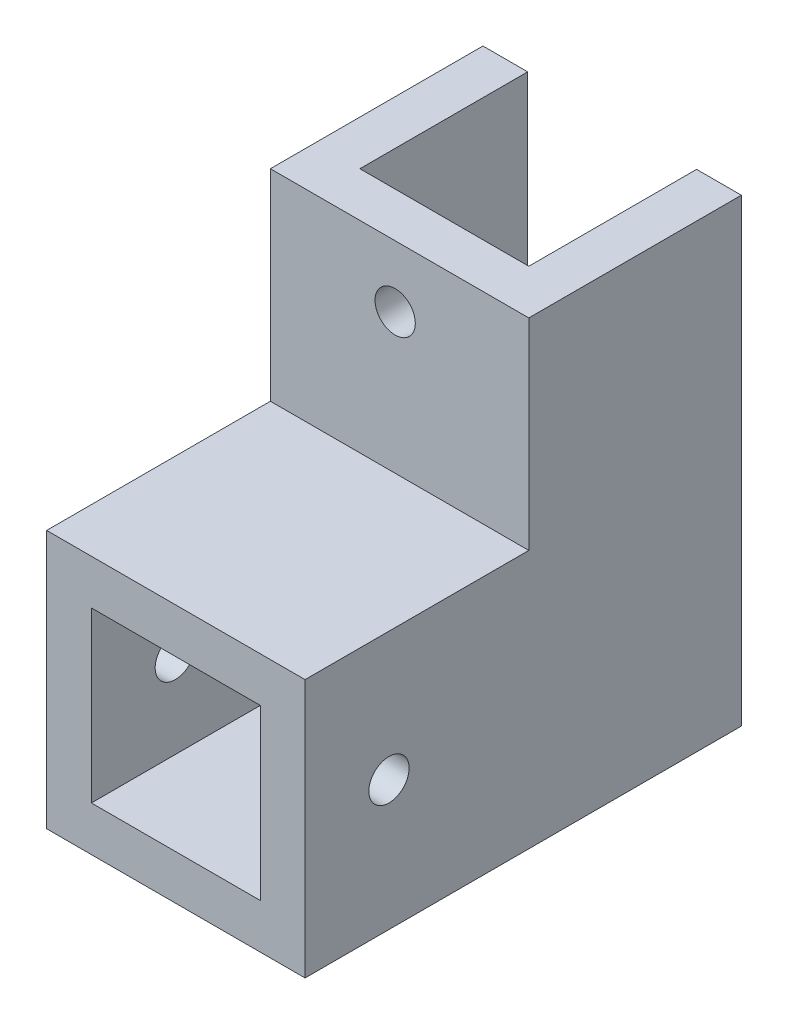
from build123d import *

# Parameters (mm, degrees)
EXTRUDE_1_DEPTH     = 20
SKETCH_2_W          = 23.1
SKETCH_2_H          = 23.1
SKETCH_2_W_2        = 15.1
SKETCH_2_H_2        = 15.1
EXTRUDE_2_DEPTH     = 24
SKETCH_3_W          = 4
SKETCH_3_H          = 23.1
EXTRUDE_3_DEPTH     = 15
SKETCH_4_R          = 1.8
CUT_EXTRUDE_1_DEPTH = 15
SKETCH_5_R          = 1.8
CUT_EXTRUDE_2_DEPTH = 35
SKETCH_6_W          = 23.1
SKETCH_6_H          = 19
CUT_EXTRUDE_3_DEPTH = 2


with BuildPart() as part:
    # 草图1 → 凸台-拉伸1 (new body)
    with BuildSketch(Plane(origin=(0, 0, 0), x_dir=(1, 0, 0), z_dir=(0, 1, 0))):
        Polygon((-11.153846154, 14.269230769), (-7.153846154, 14.269230769), (-7.153846154, -0.730769231), (7.946153846, -0.730769231), (7.946153846, 14.269230769), (11.946153846, 14.269230769), (11.946153846, -0.730769231), (11.946153846, -4.730769231), (-7.384615385, -4.730769231), (-11.153846154, -4.730769231), align=None)
    extrude(amount=EXTRUDE_1_DEPTH)

    # 草图2 → 凸台-拉伸2 (add)
    with BuildSketch(Plane(origin=(0, 0, 0.730769231), x_dir=(-1, 0, 0), z_dir=(0, 0, -1))):
        with Locations((-0.396153846, -11.55)):
            Rectangle(SKETCH_2_W, SKETCH_2_H)
        with Locations((-0.396153846, -11.55)):
            Rectangle(SKETCH_2_W_2, SKETCH_2_H_2, mode=Mode.SUBTRACT)
    extrude(amount=-EXTRUDE_2_DEPTH)

    # 草图3 → 凸台-拉伸3 (add)
    with BuildSketch(Plane(origin=(0, 0, 0.730769231), x_dir=(-1, 0, 0), z_dir=(0, 0, -1))):
        with Locations((-9.946153846, -11.55)):
            Rectangle(SKETCH_3_W, SKETCH_3_H)
        with Locations((9.153846154, -11.55)):
            Rectangle(SKETCH_3_W, SKETCH_3_H)
    extrude(amount=EXTRUDE_3_DEPTH)

    # 草图4 → 切除-拉伸1 (cut)
    with BuildSketch(Plane.XY.offset(4.730769231)):
        with Locations((0, 12.5)):
            Circle(SKETCH_4_R)
    extrude(amount=-CUT_EXTRUDE_1_DEPTH, mode=Mode.SUBTRACT)

    # 草图5 → 切除-拉伸2 (cut)
    with BuildSketch(Plane(origin=(11.946153846, 0, 0), x_dir=(0, 0, -1), z_dir=(1, 0, 0))):
        with Locations((-17.230769231, -11.5)):
            Circle(SKETCH_5_R)
    extrude(amount=-CUT_EXTRUDE_2_DEPTH, mode=Mode.SUBTRACT)

    # 草图6 → 切除-拉伸3 (cut)
    with BuildSketch(Plane(origin=(0, 20, 0), x_dir=(1, 0, 0), z_dir=(0, 1, 0))):
        with Locations((0.396153846, 4.769230769)):
            Rectangle(SKETCH_6_W, SKETCH_6_H)
    extrude(amount=-CUT_EXTRUDE_3_DEPTH, mode=Mode.SUBTRACT)


solid = part.part
